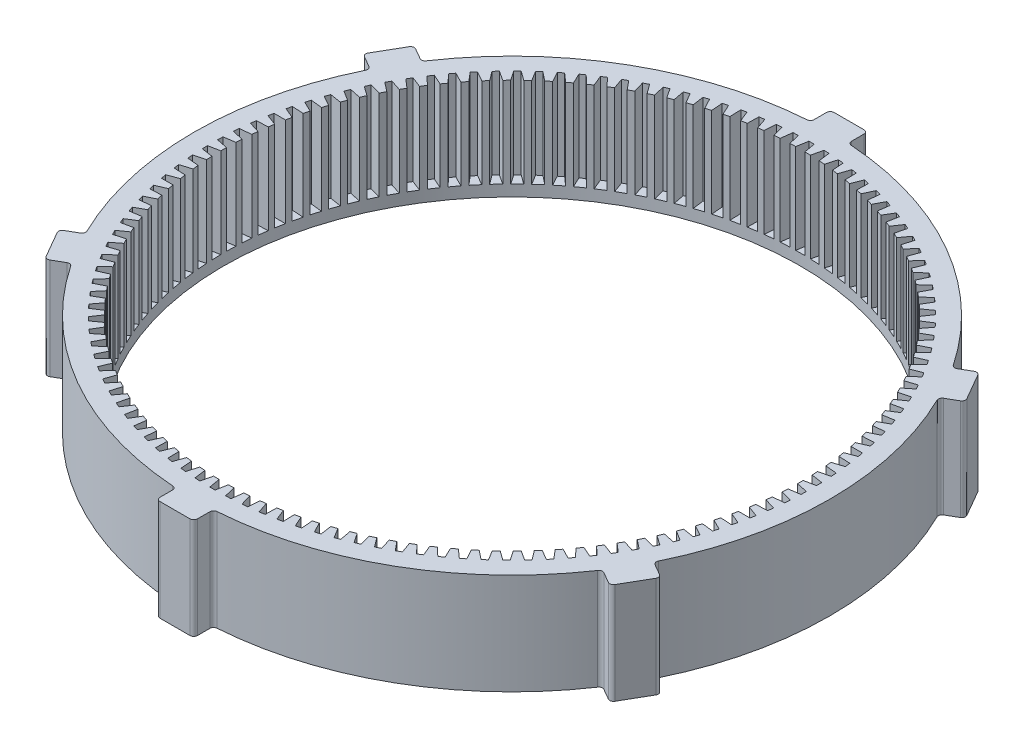
from build123d import *

# Parameters (mm, degrees)
SKETCH1_R           = 42.45
SKETCH1_R_2         = 38.5
BOSS_EXTRUDE1_DEPTH = 13.5
BOSS_EXTRUDE2_DEPTH = 13.5
CIRPATTERN1_COUNT   = 3
FILLET1_R           = 0.5
CUT_EXTRUDE1_DEPTH  = 12
CIRPATTERN2_COUNT   = 122


with BuildPart() as part:
    # Sketch1 → Boss-Extrude1 (new body)
    with BuildSketch(Plane(origin=(0, 0, 0), x_dir=(1, 0, 0), z_dir=(0, 1, 0))):
        Circle(SKETCH1_R)
        Circle(SKETCH1_R_2, mode=Mode.SUBTRACT)
    extrude(amount=BOSS_EXTRUDE1_DEPTH)

    # Sketch2 → Boss-Extrude2 (add)
    with BuildSketch(Plane(origin=(0, 0, 0), x_dir=(1, 0, 0), z_dir=(0, 1, 0))):
        with BuildLine():
            ThreePointArc((-2.5, 42.376320038), (0, 42.45), (2.5, 42.376320038))
            Line((2.5, 42.376320038), (2.5, 45))
            Line((2.5, 45), (-2.5, 45))
            Line((-2.5, 45), (-2.5, 42.376320038))
        make_face()
        with BuildLine():
            Line((-2.5, -45), (2.5, -45))
            Line((2.5, -45), (2.5, -42.376320038))
            ThreePointArc((2.5, -42.376320038), (0, -42.45), (-2.5, -42.376320038))
            Line((-2.5, -42.376320038), (-2.5, -45))
        make_face()
    boss_extrude2 = extrude(amount=BOSS_EXTRUDE2_DEPTH)

    # CirPattern1: Boss-Extrude2 ×3 about axis
    cirpattern1_axis = Axis((0, 0, 0), (0, 1, 0))
    for i in range(1, CIRPATTERN1_COUNT):
        add(boss_extrude2.rotate(cirpattern1_axis, i * 360 / CIRPATTERN1_COUNT))

    # Fillet1
    fillet1_edges = [part.edges().sort_by_distance(p)[0] for p in [
        (-2.5, 6.75, -45),
        (2.5, 6.75, -45),
        (2.5, 6.75, -42.376320038),
        (-2.5, 6.75, -42.376320038),
        (2.5, 6.75, 42.376320038),
        (-2.5, 6.75, 42.376320038),
        (-2.5, 6.75, 45),
        (2.5, 6.75, 45),
        (40.22114317, 6.75, 20.334936491),
        (37.72114317, 6.75, 24.665063509),
        (35.448969672, 6.75, 23.353223529),
        (37.948969672, 6.75, 19.02309651),
        (-37.948969672, 6.75, -19.02309651),
        (-35.448969672, 6.75, -23.353223529),
        (-37.72114317, 6.75, -24.665063509),
        (-40.22114317, 6.75, -20.334936491),
        (-37.72114317, 6.75, 24.665063509),
        (-40.22114317, 6.75, 20.334936491),
        (-37.948969672, 6.75, 19.02309651),
        (-35.448969672, 6.75, 23.353223529),
        (35.448969672, 6.75, -23.353223529),
        (37.948969672, 6.75, -19.02309651),
        (40.22114317, 6.75, -20.334936491),
        (37.72114317, 6.75, -24.665063509),
    ]]
    fillet(fillet1_edges, radius=FILLET1_R)

    # Sketch3 → Cut-Extrude1 (cut)
    with BuildSketch(Plane(origin=(0, 13.5, 0), x_dir=(1, 0, 0), z_dir=(0, 1, 0))):
        Polygon((-0.35, 40), (0.35, 40), (0.615357655, 38.495081958), (-0.615357655, 38.495081958), align=None)
    cut_extrude1 = extrude(amount=-CUT_EXTRUDE1_DEPTH, mode=Mode.SUBTRACT)

    # CirPattern2: Cut-Extrude1 ×122 about axis
    cirpattern2_axis = Axis((0, 0, 0), (0, 1, 0))
    for i in range(1, CIRPATTERN2_COUNT):
        add(cut_extrude1.rotate(cirpattern2_axis, i * 360 / CIRPATTERN2_COUNT), mode=Mode.SUBTRACT)


solid = part.part
